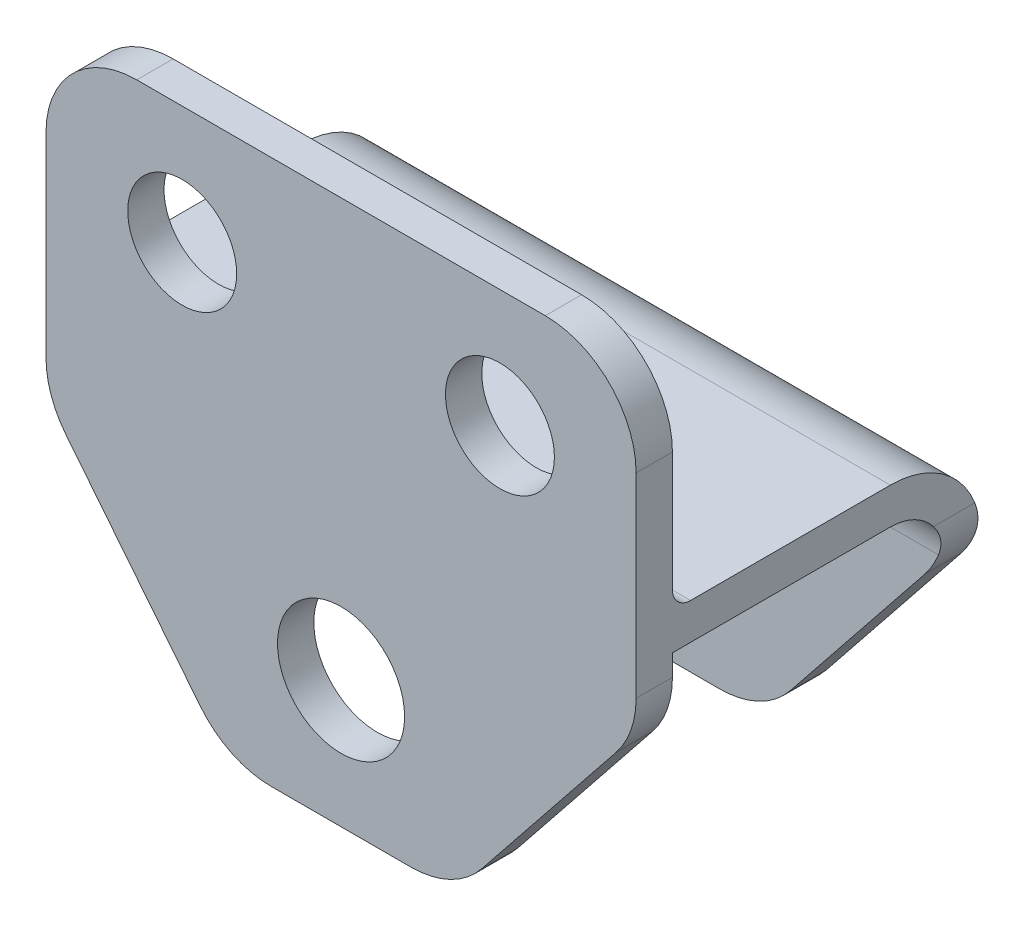
from build123d import *

# Parameters (mm, degrees)
ESQUISSE1_R                         = 6
BOSS_EXTRU_1_DEPTH                  = 4
CONG_1_R                            = 10
BOSS_EXTRU_2_REACH                  = 34.5
BOSS_EXTRU_2_DIRECTION_2_REACH      = 34.5
CONG_2_R                            = 2
ENL_V_MAT_EXTRU_1_REACH             = 6
ENL_V_MAT_EXTRU_1_DIRECTION_2_DEPTH = 5
DIAM_TRE_DU_PER_AGE_14_0_14_1_D     = 14


with BuildPart() as part:
    # Esquisse1 → Boss.-Extru.1 (new body)
    with BuildSketch(Plane.XY):
        Polygon((-32.5, -9.841659782), (-12.5, -34.841659782), (12.5, -34.841659782), (32.5, -9.841659782), (32.5, 25.158340218), (-32.5, 25.158340218), align=None)
        with Locations((-17.5, 12.158340218)):
            Circle(ESQUISSE1_R, mode=Mode.SUBTRACT)
        with Locations((17.5, 12.158340218)):
            Circle(ESQUISSE1_R, mode=Mode.SUBTRACT)
    extrude(amount=BOSS_EXTRU_1_DEPTH)

    # Congé1
    cong_1_edges = [part.edges().sort_by_distance(p)[0] for p in [
        (-32.5, 25.158340218, 2),
        (32.5, 25.158340218, 2),
        (32.5, -9.841659782, 2),
        (12.5, -34.841659782, 2),
        (-12.5, -34.841659782, 2),
        (-32.5, -9.841659782, 2),
    ]]
    fillet(cong_1_edges, radius=CONG_1_R)

    # Boss.-Extru.2: up to this face of the body (flat: up to its plane)
    boss_extru_2_end = Plane(part.part.faces().sort_by_distance((32.5, 4.412245514, 2))[0])
    # Esquisse2 → Boss.-Extru.2 (add, up to the picked face)
    with BuildSketch(Plane(origin=(0, 0, 0), x_dir=(0, 0, -1), z_dir=(1, 0, 0)), mode=Mode.PRIVATE) as boss_extru_2_sk1:
        with BuildLine():
            Line((0, 0), (24, 0))
            ThreePointArc((24, 0), (31.071067812, -2.928932188), (34, -10))
            Line((34, -10), (34, -35))
            Line((34, -35), (30, -35))
            Line((30, -35), (30, -10))
            ThreePointArc((30, -10), (28.242640687, -5.757359313), (24, -4))
            Line((24, -4), (0, -4))
            Line((0, -4), (0, 0))
        make_face()
    boss_extru_2_tool1 = split(extrude(boss_extru_2_sk1.sketch, amount=BOSS_EXTRU_2_REACH, mode=Mode.PRIVATE), bisect_by=boss_extru_2_end, keep=Keep.BOTH, mode=Mode.PRIVATE)
    add(boss_extru_2_tool1.solids().sort_by(Axis((0, -0.487955, -12), (1, 0, 0)))[0])

    # Boss.-Extru.2 direction 2: up to this face of the body (flat: up to its plane)
    boss_extru_2_direction_2_end = Plane(part.part.faces().sort_by_distance((-32.5, 4.412245514, 2))[0])
    # Esquisse2 → Boss.-Extru.2 direction 2 (add, up to the picked face)
    with BuildSketch(Plane(origin=(0, 0, 0), x_dir=(0, 0, -1), z_dir=(1, 0, 0)), mode=Mode.PRIVATE) as boss_extru_2_direction_2_sk1:
        with BuildLine():
            Line((0, 0), (24, 0))
            ThreePointArc((24, 0), (31.071067812, -2.928932188), (34, -10))
            Line((34, -10), (34, -35))
            Line((34, -35), (30, -35))
            Line((30, -35), (30, -10))
            ThreePointArc((30, -10), (28.242640687, -5.757359313), (24, -4))
            Line((24, -4), (0, -4))
            Line((0, -4), (0, 0))
        make_face()
    boss_extru_2_direction_2_tool1 = split(extrude(boss_extru_2_direction_2_sk1.sketch, amount=-BOSS_EXTRU_2_DIRECTION_2_REACH, mode=Mode.PRIVATE), bisect_by=boss_extru_2_direction_2_end, keep=Keep.BOTH, mode=Mode.PRIVATE)
    add(boss_extru_2_direction_2_tool1.solids().sort_by(Axis((0, -0.487955, -12), (-1, 0, 0)))[0])

    # Congé2
    cong_2_edges = [part.edges().sort_by_distance(p)[0] for p in [
        (0, 0, 0),
    ]]
    fillet(cong_2_edges, radius=CONG_2_R)

    # Esquisse3 → Enlèv. mat.-Extru.1 (cut, up to next)
    with BuildSketch(Plane.XY.offset(-30), mode=Mode.PRIVATE) as enl_v_mat_extru_1_sk1:
        with BuildLine():
            Line((-32.5, -6.333849189), (-38.653299958, -6.333849189))
            Line((-38.653299958, -6.333849189), (-39.385367291, -42.953606415))
            Line((-39.385367291, -42.953606415), (40.318463565, -42.953606415))
            Line((40.318463565, -42.953606415), (40.318463565, -6.333849189))
            Line((40.318463565, -6.333849189), (32.5, -6.333849189))
            ThreePointArc((32.5, -6.333849189), (31.936283192, -9.643918603), (30.308688094, -12.580799664))
            Line((30.308688094, -12.580799664), (15.50243962, -31.088610258))
            ThreePointArc((15.50243962, -31.088610258), (12.02563883, -33.854692146), (7.693751525, -34.841659782))
            Line((7.693751525, -34.841659782), (-7.693751525, -34.841659782))
            ThreePointArc((-7.693751525, -34.841659782), (-12.02563883, -33.854692146), (-15.50243962, -31.088610258))
            Line((-15.50243962, -31.088610258), (-30.308688094, -12.580799664))
            ThreePointArc((-30.308688094, -12.580799664), (-31.936283192, -9.643918603), (-32.5, -6.333849189))
        make_face()
    enl_v_mat_extru_1_tool1 = extrude(enl_v_mat_extru_1_sk1.sketch, amount=-ENL_V_MAT_EXTRU_1_REACH, mode=Mode.PRIVATE) & part.part
    add(enl_v_mat_extru_1_tool1.solids().sort_by_distance((-35.57665, -7.210987, -30))[0], mode=Mode.SUBTRACT)

    # Esquisse3 → Enlèv. mat.-Extru.1 direction 2 (cut)
    with BuildSketch(Plane.XY.offset(-30)):
        with BuildLine():
            Line((-32.5, -6.333849189), (-38.653299958, -6.333849189))
            Line((-38.653299958, -6.333849189), (-39.385367291, -42.953606415))
            Line((-39.385367291, -42.953606415), (40.318463565, -42.953606415))
            Line((40.318463565, -42.953606415), (40.318463565, -6.333849189))
            Line((40.318463565, -6.333849189), (32.5, -6.333849189))
            ThreePointArc((32.5, -6.333849189), (31.936283192, -9.643918603), (30.308688094, -12.580799664))
            Line((30.308688094, -12.580799664), (15.50243962, -31.088610258))
            ThreePointArc((15.50243962, -31.088610258), (12.02563883, -33.854692146), (7.693751525, -34.841659782))
            Line((7.693751525, -34.841659782), (-7.693751525, -34.841659782))
            ThreePointArc((-7.693751525, -34.841659782), (-12.02563883, -33.854692146), (-15.50243962, -31.088610258))
            Line((-15.50243962, -31.088610258), (-30.308688094, -12.580799664))
            ThreePointArc((-30.308688094, -12.580799664), (-31.936283192, -9.643918603), (-32.5, -6.333849189))
        make_face()
    extrude(amount=ENL_V_MAT_EXTRU_1_DIRECTION_2_DEPTH, mode=Mode.SUBTRACT)

    # Diamètre du perçage Ø14.0 (14)1 (through all)
    with Locations(Plane.XY.offset(4)):
        with Locations((0, -20.841659782)):
            Hole(DIAM_TRE_DU_PER_AGE_14_0_14_1_D / 2)


solid = part.part
